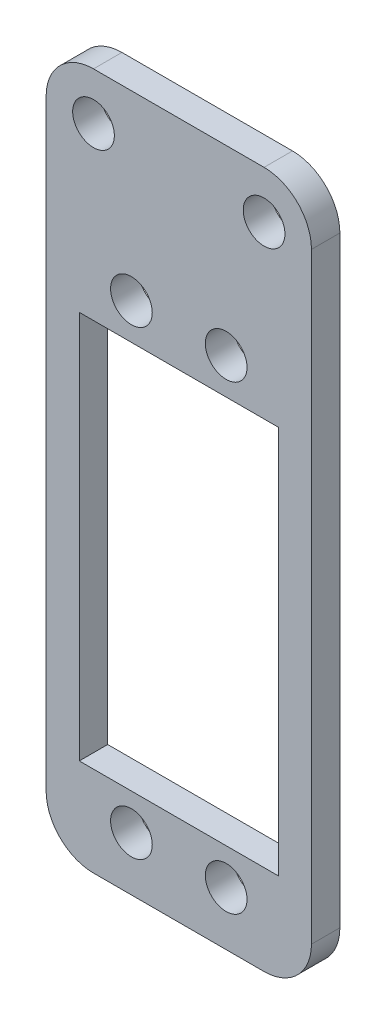
from build123d import *

# Parameters (mm, degrees)
EXTRUDE_1_DEPTH     = 3
SKETCH_3_R          = 2.2
SKETCH_3_W          = 21
SKETCH_3_H          = 41
CUT_EXTRUDE_1_DEPTH = 4
SKETCH_4_R          = 2.2
CUT_EXTRUDE_2_DEPTH = 4


with BuildPart() as part:
    # 草图2 → 凸台-拉伸1 (new body)
    with BuildSketch(Plane.XY):
        with BuildLine():
            Line((-9, -33.5), (9, -33.5))
            ThreePointArc((9, -33.5), (12.535533906, -32.035533906), (14, -28.5))
            Line((14, -28.5), (14, 35))
            ThreePointArc((14, 35), (12.535533906, 38.535533906), (9, 40))
            Line((9, 40), (-9, 40))
            ThreePointArc((-9, 40), (-12.535533906, 38.535533906), (-14, 35))
            Line((-14, 35), (-14, -28.5))
            ThreePointArc((-14, -28.5), (-12.535533906, -32.035533906), (-9, -33.5))
        make_face()
    extrude(amount=EXTRUDE_1_DEPTH)

    # 草图3 → 切除-拉伸1 (cut, through all)
    with BuildSketch(Plane.XY.offset(3)):
        with Locations((-5, 20.815)):
            Circle(SKETCH_3_R)
        with Locations((-5, -27.815)):
            Circle(SKETCH_3_R)
        with Locations((0, -3.5)):
            Rectangle(SKETCH_3_W, SKETCH_3_H)
        with Locations((5, -27.815)):
            Circle(SKETCH_3_R)
        with Locations((5, 20.815)):
            Circle(SKETCH_3_R)
    extrude(amount=-CUT_EXTRUDE_1_DEPTH, mode=Mode.SUBTRACT)

    # 草图4 → 切除-拉伸2 (cut, through all)
    with BuildSketch(Plane.XY.offset(3)):
        with Locations((-9, 35)):
            Circle(SKETCH_4_R)
        with Locations((9, 35)):
            Circle(SKETCH_4_R)
    extrude(amount=-CUT_EXTRUDE_2_DEPTH, mode=Mode.SUBTRACT)


solid = part.part
